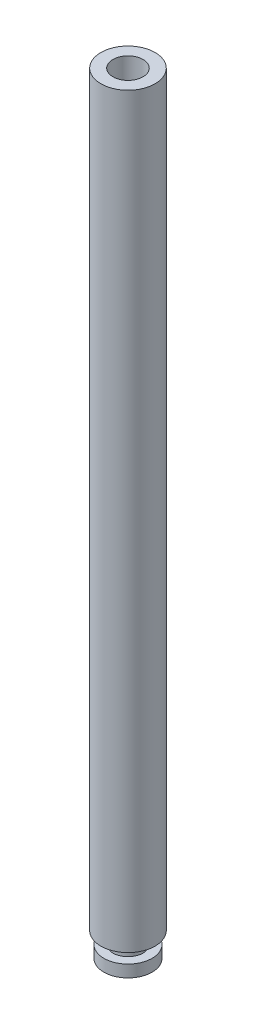
from build123d import *

# Parameters (mm, degrees)
SKETCH1_R           = 2.25
BOSS_EXTRUDE1_DEPTH = 62
SKETCH1_3_R         = 1
BOSS_EXTRUDE2_DEPTH = 1
SKETCH5_R           = 1.25
BOSS_EXTRUDE3_DEPTH = 1
SKETCH6_R           = 2
BOSS_EXTRUDE4_DEPTH = 1
SKETCH12_R          = 1.25
CUT_EXTRUDE1_DEPTH  = 5


with BuildPart() as part:
    # Sketch1 → Boss-Extrude1 (new body)
    with BuildSketch(Plane(origin=(0, 0, 0), x_dir=(1, 0, 0), z_dir=(0, 1, 0))):
        with Locations((-0.522013312, 0.511138034)):
            Circle(SKETCH1_R)
    extrude(amount=BOSS_EXTRUDE1_DEPTH)

    # Sketch1_3 → Boss-Extrude2 (add)
    with BuildSketch(Plane(origin=(0, 0, 0), x_dir=(1, 0, 0), z_dir=(0, 1, 0))):
        with Locations((-0.522013312, 0.511138034)):
            Circle(SKETCH1_3_R)
    extrude(amount=BOSS_EXTRUDE2_DEPTH)

    # Sketch5 → Boss-Extrude3 (add)
    with BuildSketch(Plane.XZ):
        with Locations((-0.522013312, -0.511138034)):
            Circle(SKETCH5_R)
    extrude(amount=BOSS_EXTRUDE3_DEPTH)

    # Sketch6 → Boss-Extrude4 (add)
    with BuildSketch(Plane.XZ.offset(1)):
        with Locations((-0.522013312, -0.511138034)):
            Circle(SKETCH6_R)
    extrude(amount=BOSS_EXTRUDE4_DEPTH)

    # Sketch12 → Cut-Extrude1 (cut)
    with BuildSketch(Plane(origin=(0, 62, 0), x_dir=(1, 0, 0), z_dir=(0, 1, 0))):
        with Locations((-0.522013312, 0.511138034)):
            Circle(SKETCH12_R)
    extrude(amount=-CUT_EXTRUDE1_DEPTH, mode=Mode.SUBTRACT)


solid = part.part
